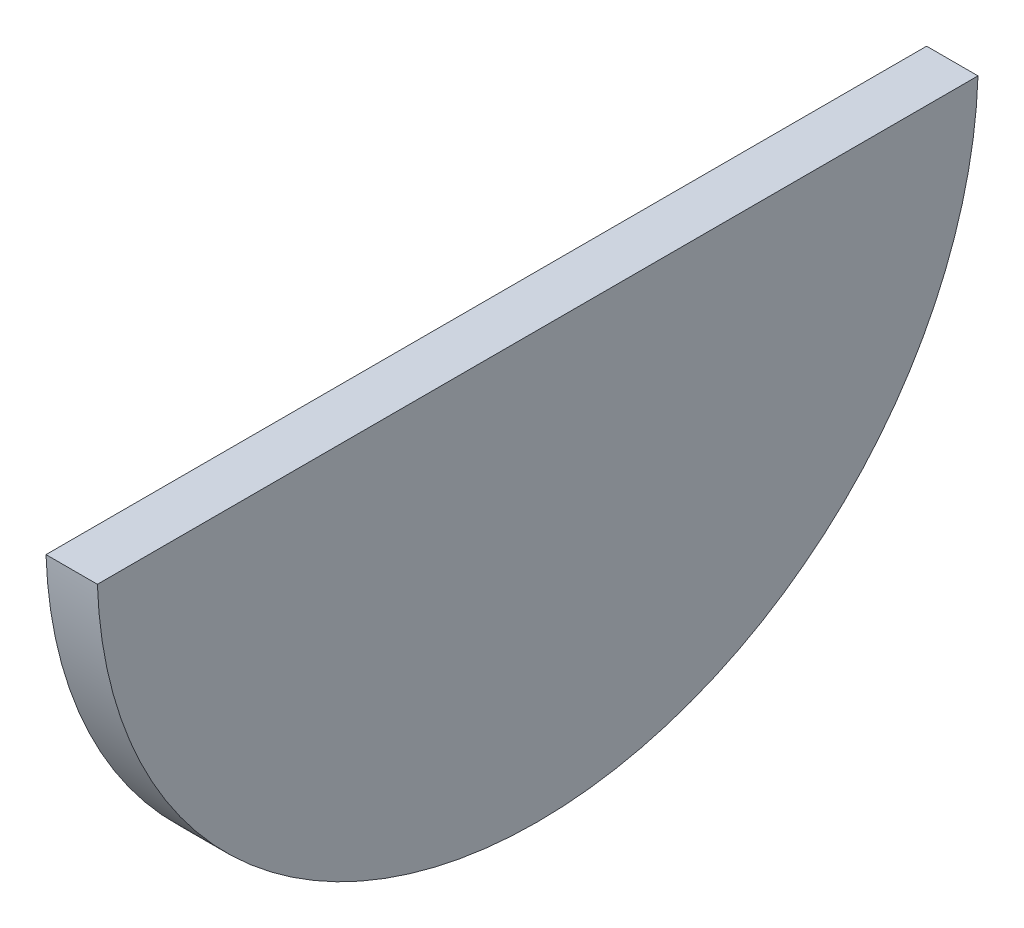
from build123d import *

# Parameters (mm, degrees)
BOSS_EXTRUDE1_DEPTH = 8.89


with BuildPart() as part:
    # Sketch1 → Boss-Extrude1 (new body)
    with BuildSketch(Plane(origin=(0, 0, 0), x_dir=(0, 0, -1), z_dir=(1, 0, 0))):
        with BuildLine():
            Line((76.157654901, 0), (-76.157654901, 0))
            ThreePointArc((-76.157654901, 0), (0, -73.66), (76.157654901, 0))
        make_face()
    extrude(amount=BOSS_EXTRUDE1_DEPTH)


solid = part.part
